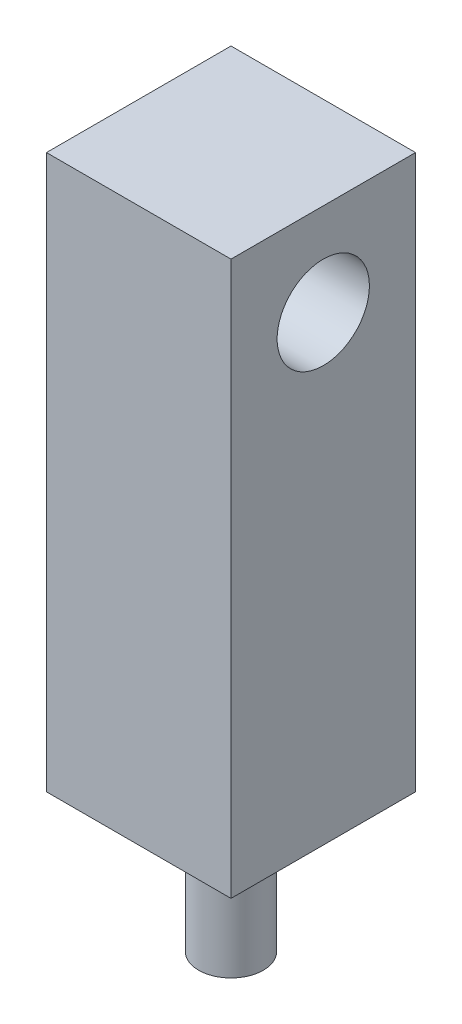
from build123d import *

# Parameters (mm, degrees)
SKETCH2_W           = 4
SKETCH2_H           = 4
BOSS_EXTRUDE1_DEPTH = 12
SKETCH3_R           = 0.7
BOSS_EXTRUDE2_DEPTH = 3
SKETCH4_R           = 1
CUT_EXTRUDE1_DEPTH  = 3


with BuildPart() as part:
    # Sketch2 → Boss-Extrude1 (new body)
    with BuildSketch(Plane(origin=(0, 0, 0), x_dir=(1, 0, 0), z_dir=(0, 1, 0))):
        Rectangle(SKETCH2_W, SKETCH2_H)
    extrude(amount=BOSS_EXTRUDE1_DEPTH)

    # Sketch3 → Boss-Extrude2 (add)
    with BuildSketch(Plane(origin=(0, 0, 0), x_dir=(1, 0, 0), z_dir=(0, 1, 0))):
        Circle(SKETCH3_R)
    extrude(amount=-BOSS_EXTRUDE2_DEPTH)

    # Sketch4 → Cut-Extrude1 (cut)
    with BuildSketch(Plane(origin=(2, 0, 0), x_dir=(0, 0, -1), z_dir=(1, 0, 0))):
        with Locations((0, 10)):
            Circle(SKETCH4_R)
    extrude(amount=-CUT_EXTRUDE1_DEPTH, mode=Mode.SUBTRACT)


solid = part.part
